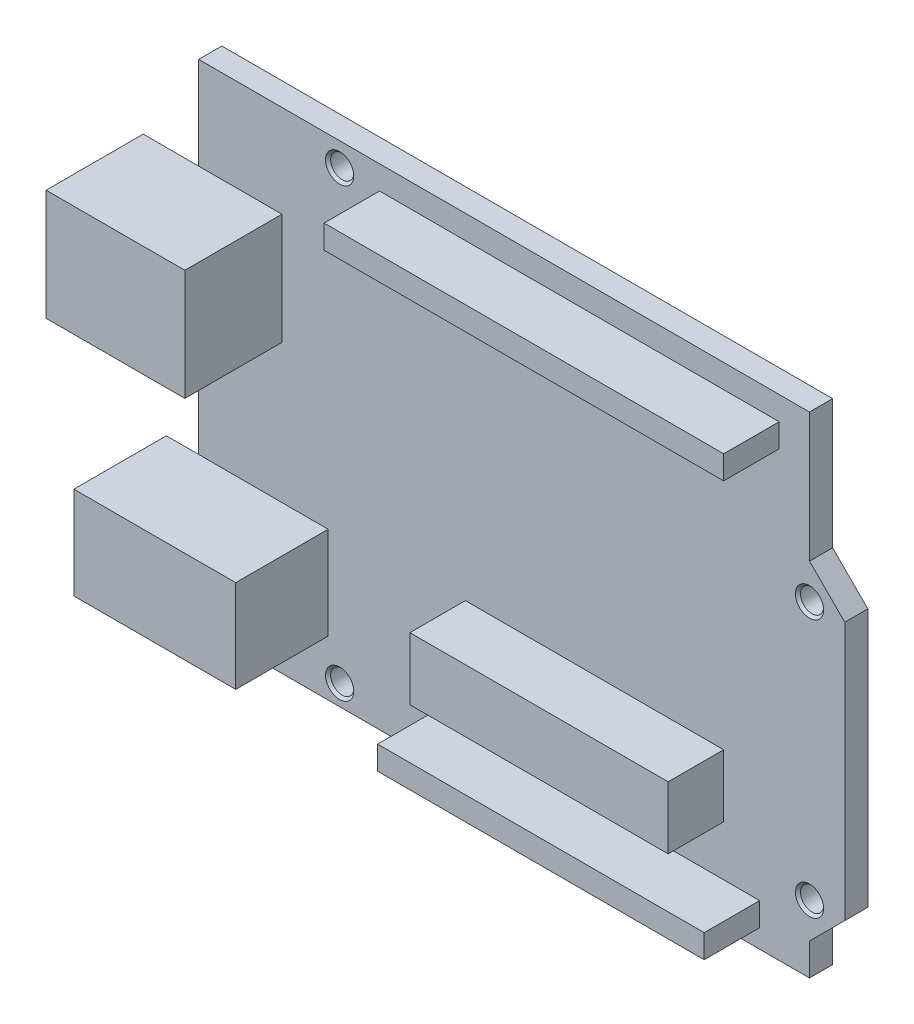
from build123d import *

# Parameters (mm, degrees)
EXTRUDE_1_DEPTH              = 2.5
HOLE_WIZARD_M3_1_D           = 2.5
HOLE_WIZARD_M3_1_CSINK_D     = 3.05
HOLE_WIZARD_M3_1_CSINK_ANGLE = 90
SKETCH_8_W                   = 27.92487284
SKETCH_8_H                   = 6.74765502
SKETCH_8_W_2                 = 35.307317085
SKETCH_8_H_2                 = 2.5392143
SKETCH_8_W_3                 = 43.206671158
EXTRUDE_2_DEPTH              = 6
SKETCH_9_W                   = 15
SKETCH_9_H                   = 12
EXTRUDE_3_DEPTH              = 10.5
SKETCH_10_W                  = 2.54775384
SKETCH_10_H                  = 5.1401971
CUT_EXTRUDE_1_DEPTH          = 10.5
SKETCH_12_W                  = 14
SKETCH_12_H                  = 10
EXTRUDE_4_DEPTH              = 10
SKETCH_13_W                  = 10
SKETCH_13_H                  = 10
SKETCH_13_R                  = 2.75
EXTRUDE_5_DEPTH              = 3.5
SKETCH_14_R                  = 2.75
CUT_EXTRUDE_3_DEPTH          = 8


with BuildPart() as part:
    # 草图1 → 凸台-拉伸1 (new body)
    with BuildSketch(Plane.XY):
        Polygon((-35.4452235, 28.536703393), (-35.4452235, -24.463296607), (30.5947765, -24.463296607), (30.5947765, -20.997866899), (34.409346792, -17.183296607), (34.409346792, 10.756703393), (30.5947765, 14.571273684), (30.5947765, 28.536703393), align=None)
    extrude(amount=EXTRUDE_1_DEPTH)

    # M3 螺纹孔1 (through all)
    with Locations(Plane.XY.offset(2.5)):
        with Locations((-20.2052235, 25.996703393), (30.5947765, 10.756703393), (30.5947765, -17.183296607), (-20.2052235, -22.263296607)):
            CounterSinkHole(HOLE_WIZARD_M3_1_D / 2, HOLE_WIZARD_M3_1_CSINK_D / 2, counter_sink_angle=HOLE_WIZARD_M3_1_CSINK_ANGLE)

    # 草图8 → 凸台-拉伸2 (add)
    with BuildSketch(Plane.XY.offset(2.5)):
        with Locations((7.351969456, -11.104054762)):
            Rectangle(SKETCH_8_W, SKETCH_8_H)
        with Locations((7.55461376, -21.179250047)):
            Rectangle(SKETCH_8_W_2, SKETCH_8_H_2)
        with Locations((5.71151473, 24.713414732)):
            Rectangle(SKETCH_8_W_3, SKETCH_8_H_2)
    extrude(amount=EXTRUDE_2_DEPTH)

    # 草图9 → 凸台-拉伸3 (add)
    with BuildSketch(Plane.XY.offset(2.5)):
        with Locations((-33.9452235, 12.536703393)):
            Rectangle(SKETCH_9_W, SKETCH_9_H)
    extrude(amount=EXTRUDE_3_DEPTH)

    # 草图10 → 切除-拉伸1 (cut)
    with BuildSketch(Plane.ZY.offset(41.4452235)):
        Polygon((3.5, 17.344772898), (3.5, 7.728633887), (9.323306646, 7.728633887), (12, 9.706966862), (12, 15.452627596), (9.323306646, 17.344772898), align=None)
        with Locations((7.507872917, 12.536703393)):
            Rectangle(SKETCH_10_W, SKETCH_10_H, mode=Mode.SUBTRACT)
    extrude(amount=-CUT_EXTRUDE_1_DEPTH, mode=Mode.SUBTRACT)

    # 草图12 → 凸台-拉伸4 (add)
    with BuildSketch(Plane.XY.offset(2.5)):
        with Locations((-28.4452235, -13.463296607)):
            Rectangle(SKETCH_12_W, SKETCH_12_H)
    extrude(amount=EXTRUDE_4_DEPTH)

    # 草图13 → 凸台-拉伸5 (add)
    with BuildSketch(Plane.ZY.offset(35.4452235)):
        with Locations((7.5, -13.463296607)):
            Rectangle(SKETCH_13_W, SKETCH_13_H)
        with Locations((7.5, -13.463296607)):
            Circle(SKETCH_13_R, mode=Mode.SUBTRACT)
    extrude(amount=EXTRUDE_5_DEPTH)

    # 草图14 → 切除-拉伸3 (cut)
    with BuildSketch(Plane.ZY.offset(35.4452235)):
        with Locations((7.5, -13.463296607)):
            Circle(SKETCH_14_R)
    extrude(amount=-CUT_EXTRUDE_3_DEPTH, mode=Mode.SUBTRACT)


solid = part.part
